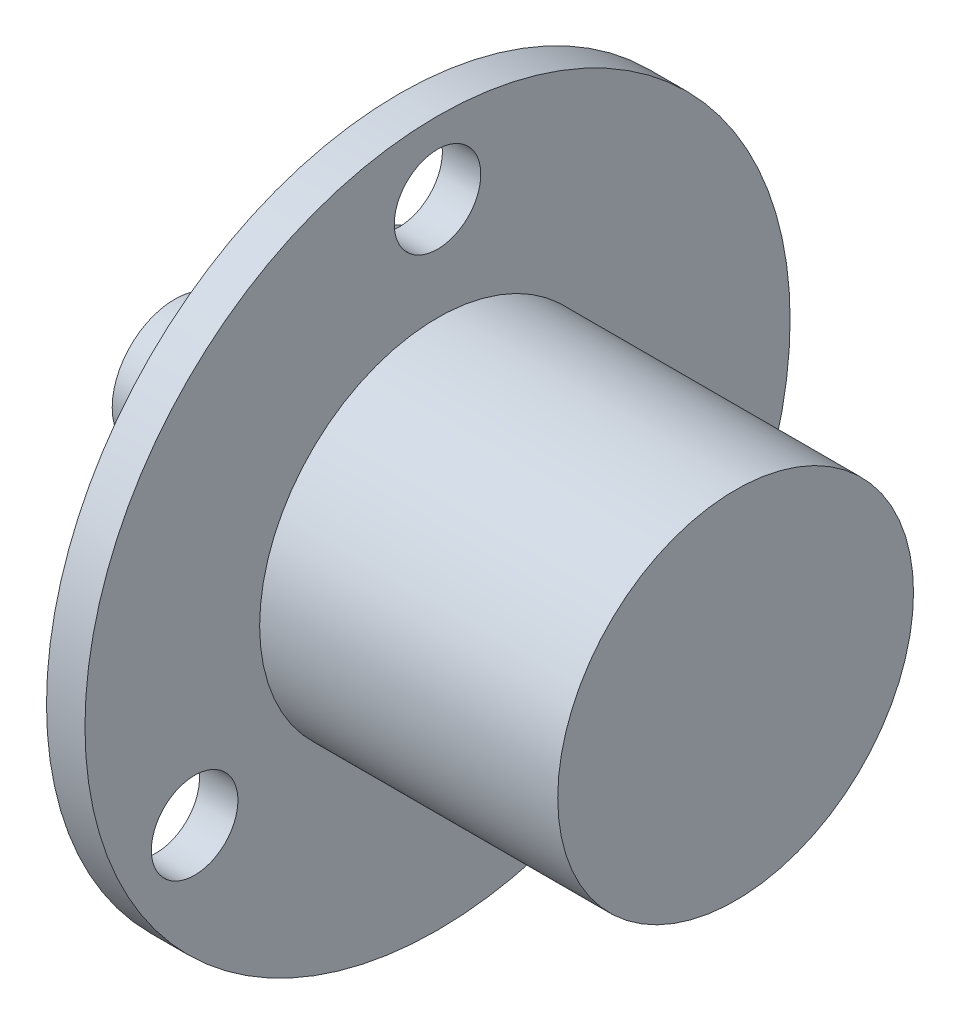
from build123d import *

# Parameters (mm, degrees)
SKETCH2_R          = 2.7
CUT_EXTRUDE1_DEPTH = 22


with BuildPart() as part:
    # Sketch1 → Revolve1 (revolve)
    with BuildSketch(Plane.XY):
        Polygon((0, 0), (35, 0), (35, 11.1), (16.4, 11.1), (16.4, 22), (14, 22), (14, 11.1), (9, 11.1), (9, 3.9), (0, 3.9), align=None)
    revolve(axis=Axis((0, 0, 0), (1, 0, 0)))

    # Sketch2 → Cut-Extrude1 (cut, through all)
    with BuildSketch(Plane.ZY.offset(-14)):
        with Locations((0, 17.5)):
            Circle(SKETCH2_R)
        with Locations((15.155444566, -8.75)):
            Circle(SKETCH2_R)
        with Locations((-15.155444566, -8.75)):
            Circle(SKETCH2_R)
    extrude(amount=-CUT_EXTRUDE1_DEPTH, mode=Mode.SUBTRACT)


solid = part.part
